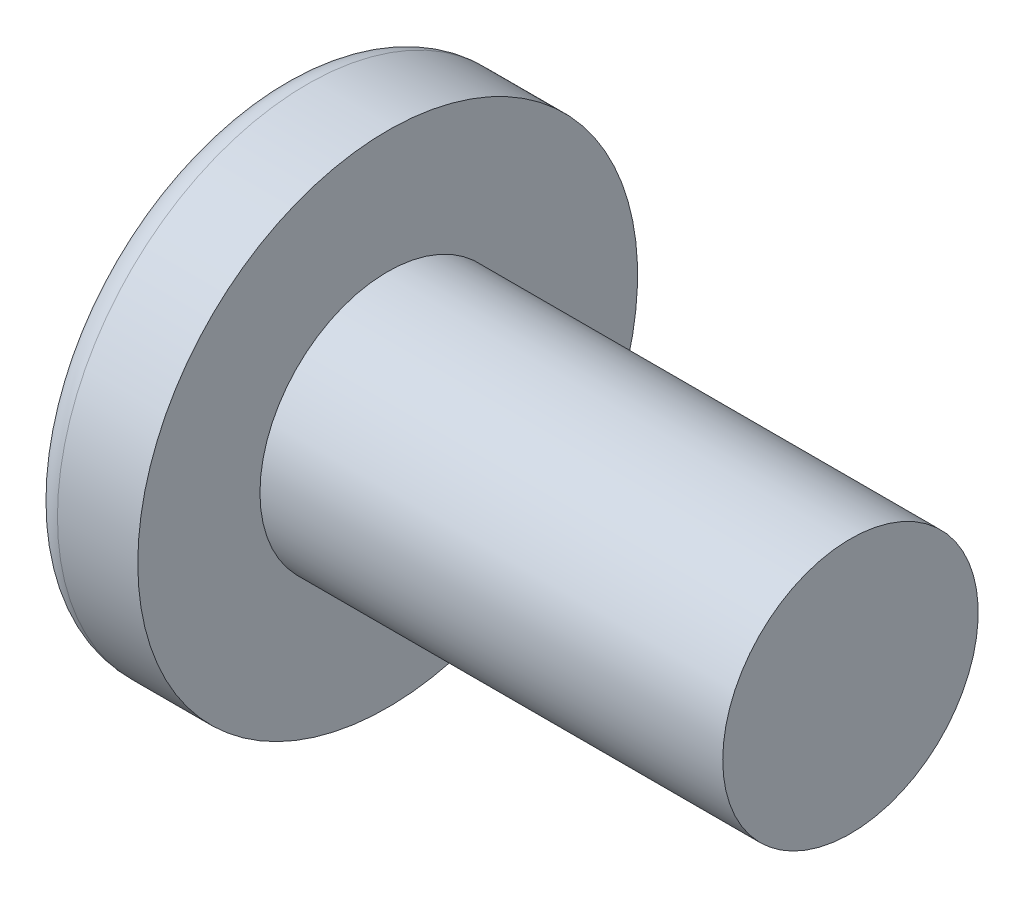
from build123d import *

# Parameters (mm, degrees)
SKETCH3_W         = 0.9398
SKETCH3_H         = 4.4704
SKETCH4_W         = 0.4699
SKETCH4_H         = 0.4699
CIRPATTERN1_COUNT = 2
CIRPATTERN1_ANGLE = 90


with BuildPart() as part:
    # BodySke → Base-Revolve (revolve)
    with BuildSketch(Plane.XY):
        with BuildLine():
            Line((2.4638, 1.7526), (2.4638, 3.429))
            Line((2.4638, 3.429), (1.361607109, 3.429))
            ThreePointArc((1.361607109, 3.429), (1.187654504, 3.386971225), (1.05207993, 3.270157434))
            ThreePointArc((1.05207993, 3.270157434), (0.269494964, 1.717614758), (0, 0))
            Line((0, 0), (8.8138, 0))
            Line((8.8138, 0), (8.8138, 1.7526))
            Line((8.8138, 1.7526), (2.4638, 1.7526))
        make_face()
    revolve(axis=Axis((-25.4, 0, 0), (1, 0, 0)))

    # Sketch3 → Cut-Loft1 section 0
    with BuildSketch(Plane(origin=(0, 0, 0), x_dir=(0, 0, -1), z_dir=(1, 0, 0))):
        Rectangle(SKETCH3_W, SKETCH3_H)
    # Sketch4 → Cut-Loft1 section 1
    with BuildSketch(Plane(origin=(2.4384, 0, 0), x_dir=(0, 0, -1), z_dir=(1, 0, 0))):
        Rectangle(SKETCH4_W, SKETCH4_H)
    cut_loft1 = loft(mode=Mode.SUBTRACT)

    # CirPattern1: Cut-Loft1 ×2 about axis
    cirpattern1_axis = Axis((0, 0, 0), (1, 0, 0))
    for i in range(1, CIRPATTERN1_COUNT):
        add(cut_loft1.rotate(cirpattern1_axis, i * CIRPATTERN1_ANGLE / (CIRPATTERN1_COUNT - 1)), mode=Mode.SUBTRACT)


solid = part.part
